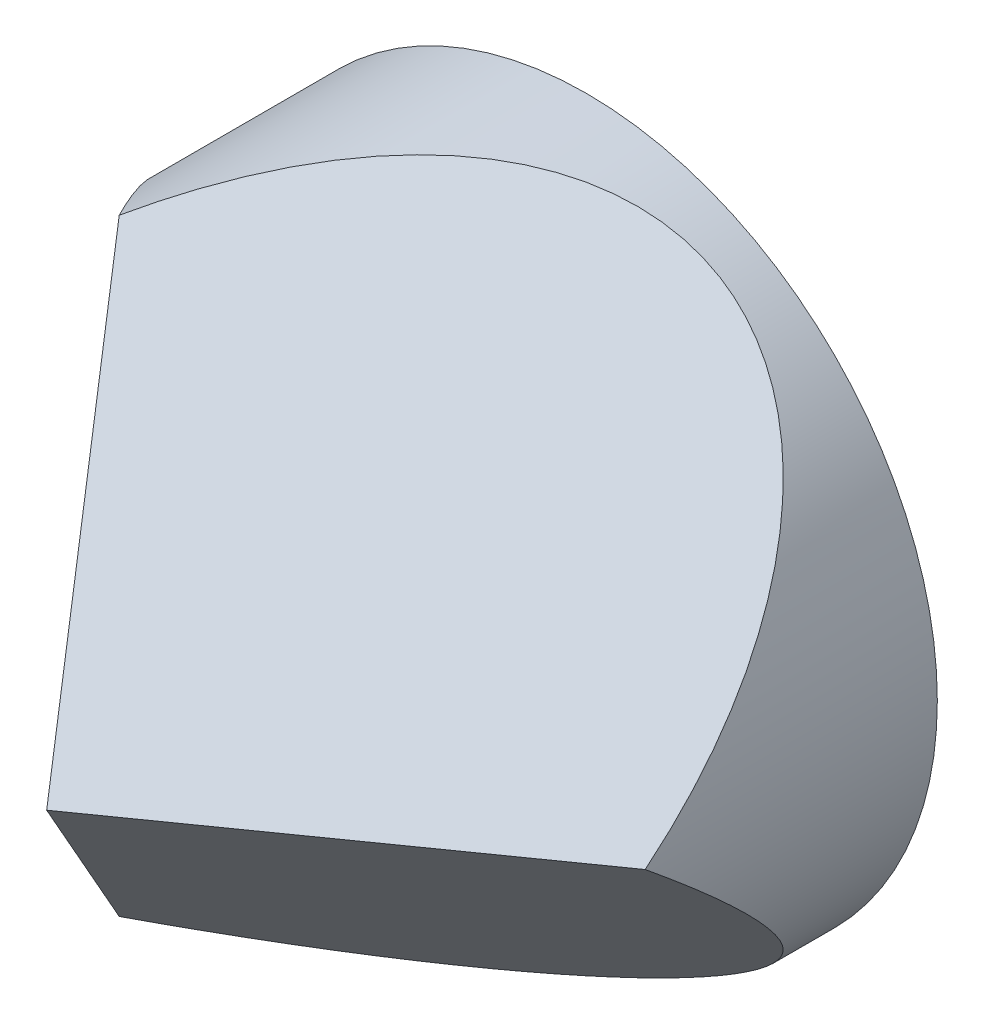
from build123d import *

# Parameters (mm, degrees)
SKETCH_1_R          = 31.1
EXTRUDE_1_DEPTH     = 47.9
CUT_EXTRUDE_1_DEPTH = 39.5
CUT_EXTRUDE_2_DEPTH = 62
CUT_EXTRUDE_3_DEPTH = 53.5


with BuildPart() as part:
    # 草图1 → 凸台-拉伸1 (new body)
    with BuildSketch(Plane.XY):
        Circle(SKETCH_1_R)
    extrude(amount=EXTRUDE_1_DEPTH)

    # 草图2 → 切除-拉伸1 (cut, symmetric)
    with BuildSketch(Plane(origin=(0, 0, 0), x_dir=(1, 0, 0), z_dir=(0, 1, 0))):
        Polygon((0, -47.9), (-40.690324156, 9.632856926), (-40.690324156, -56.656954578), (0, -56.656954578), align=None)
    extrude(amount=CUT_EXTRUDE_1_DEPTH, both=True, mode=Mode.SUBTRACT)

    # 草图4 → 切除-拉伸2 (cut, symmetric)
    with BuildSketch(Plane(origin=(0, 0, 0), x_dir=(0.5, 0.866025404, 0), z_dir=(0.866025404, -0.5, 0))):
        Polygon((0, 47.9), (100.699346514, -94.480804669), (100.699346514, 79.089205692), (0, 79.089205692), align=None)
    extrude(amount=CUT_EXTRUDE_2_DEPTH, both=True, mode=Mode.SUBTRACT)

    # 草图5 → 切除-拉伸3 (cut, symmetric)
    with BuildSketch(Plane(origin=(0, 0, 0), x_dir=(0.5, -0.866025404, 0), z_dir=(-0.866025404, -0.5, 0))):
        Polygon((0, 47.9), (45.690289371, -16.702406981), (45.690289371, 62.081252558), (2.684670532, 62.081252558), align=None)
    extrude(amount=CUT_EXTRUDE_3_DEPTH, both=True, mode=Mode.SUBTRACT)


solid = part.part
